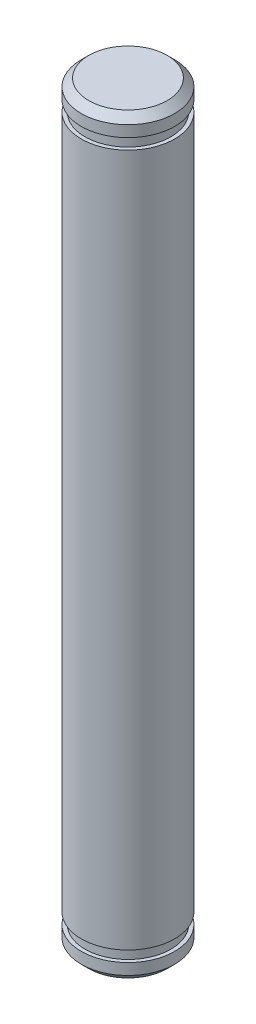
from build123d import *

# Parameters (mm, degrees)
CHAMFER1_SIZE = 0.508


with BuildPart() as part:
    # Sketch1 → Revolve1 (revolve)
    with BuildSketch(Plane.XY):
        Polygon((-3.175, 23.5585), (-3.175, -23.5585), (-2.921, -23.5585), (-2.921, -24.2951), (-3.175, -24.2951), (-3.175, -25.5651), (0, -25.5651), (0, 25.5651), (-3.175, 25.5651), (-3.175, 24.2951), (-2.921, 24.2951), (-2.921, 23.5585), align=None)
    revolve(axis=Axis((0, 25.5651, 0), (0, -1, 0)))

    # Chamfer1
    chamfer1_edges = [part.edges().sort_by_distance(p)[0] for p in [
        (3.175, -25.5651, 0),
        (3.175, 25.5651, 0),
    ]]
    chamfer(chamfer1_edges, length=CHAMFER1_SIZE)


solid = part.part
